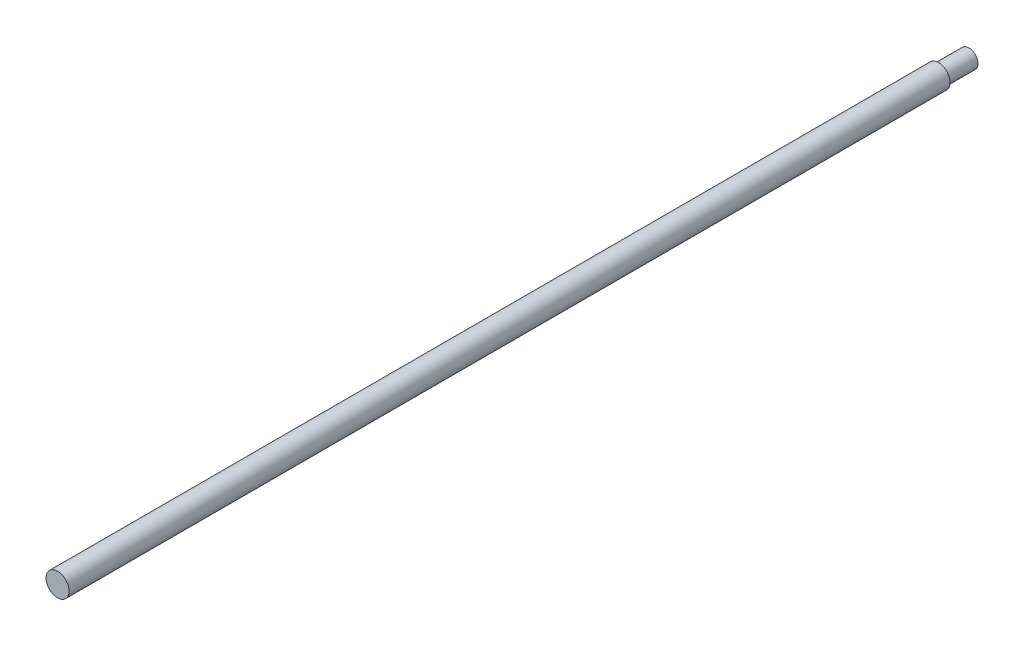
from build123d import *

# Parameters (mm, degrees)
SKETCH1_R           = 3.8
BOSS_EXTRUDE1_DEPTH = 300
SKETCH2_OUTSIDE_W   = 69.638
SKETCH2_OUTSIDE_H   = 69.638
SKETCH2_OUTSIDE_R   = 3
CUT_EXTRUDE1_DEPTH  = 10


with BuildPart() as part:
    # Sketch1 → Boss-Extrude1 (new body)
    with BuildSketch(Plane.XY):
        Circle(SKETCH1_R)
    extrude(amount=BOSS_EXTRUDE1_DEPTH)

    # Sketch2 outside → Cut-Extrude1 (cut)
    with BuildSketch(Plane(origin=(0, 0, 0), x_dir=(-1, 0, 0), z_dir=(0, 0, -1))):
        Rectangle(SKETCH2_OUTSIDE_W, SKETCH2_OUTSIDE_H)
        Circle(SKETCH2_OUTSIDE_R, mode=Mode.SUBTRACT)
    extrude(amount=-CUT_EXTRUDE1_DEPTH, mode=Mode.SUBTRACT)


solid = part.part
